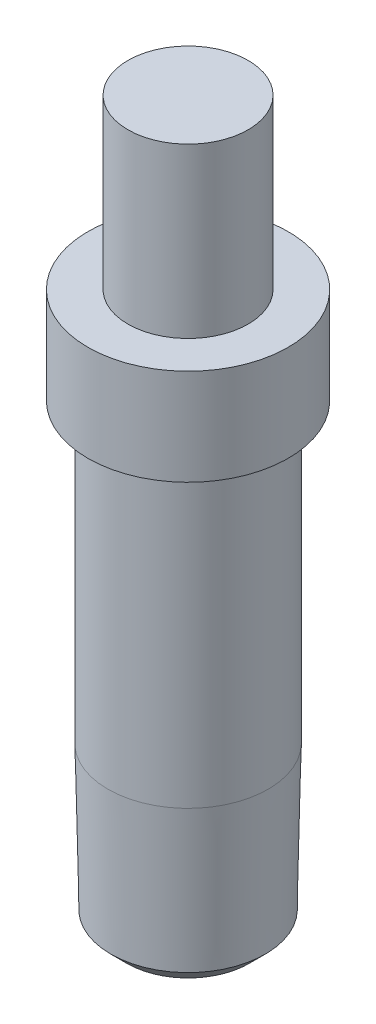
from build123d import *

# Parameters (mm, degrees)
SKETCH2_R           = 1.25
BOSS_EXTRUDE1_DEPTH = 9


with BuildPart() as part:
    # Sketch2 → Boss-Extrude1 (new body)
    with BuildSketch(Plane(origin=(0, 0, 0), x_dir=(1, 0, 0), z_dir=(0, 1, 0))):
        Circle(SKETCH2_R)
    extrude(amount=BOSS_EXTRUDE1_DEPTH)

    # Sketch4 → Cut-Revolve1 (revolve, cut)
    with BuildSketch(Plane.XY):
        Polygon((0.75, 9), (0.75, 6.9), (1.25, 6.9), (1.25, 5.7), (1, 5.7), (1, 2), (0.963866832, 0.2), (0.763866832, 0), (1.75, 0), (1.75, 9), align=None)
    revolve(axis=Axis((0, 9, 0), (0, -1, 0)), mode=Mode.SUBTRACT)


solid = part.part
